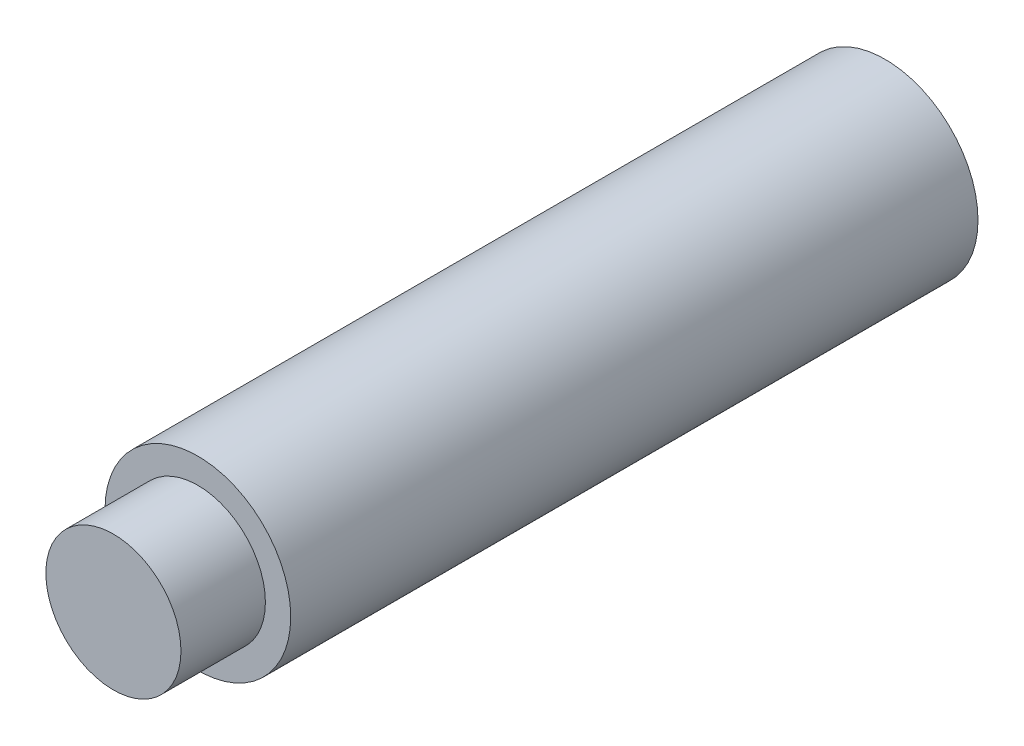
from build123d import *

# Parameters (mm, degrees)
TAP_DRILL_FOR_M6X1_0_TAP1_D     = 5
TAP_DRILL_FOR_M6X1_0_TAP1_DEPTH = 7
TAP_DRILL_FOR_M6X1_0_TAP1_TIP   = 1.502151548


with BuildPart() as part:
    # Sketch2 → Revolve1 (revolve)
    with BuildSketch(Plane(origin=(0, 0, 0), x_dir=(0, 0, -1), z_dir=(1, 0, 0))):
        Polygon((0, 0), (45.7, 0), (45.7, 5.5), (5, 5.5), (5, 4), (0, 4), align=None)
    revolve(axis=Axis((0, 0, 0), (0, 0, -1)))

    # Tap Drill for M6x1.0 Tap1
    with Locations(Plane(origin=(0, 0, -45.7), x_dir=(-1, 0, 0), z_dir=(0, 0, -1))):
        with Locations((0, 0)):
            Hole(TAP_DRILL_FOR_M6X1_0_TAP1_D / 2, depth=TAP_DRILL_FOR_M6X1_0_TAP1_DEPTH)
            with Locations((0, 0, -(TAP_DRILL_FOR_M6X1_0_TAP1_DEPTH + TAP_DRILL_FOR_M6X1_0_TAP1_TIP / 2))):  # 118° drill point
                Cone(0, TAP_DRILL_FOR_M6X1_0_TAP1_D / 2, TAP_DRILL_FOR_M6X1_0_TAP1_TIP, mode=Mode.SUBTRACT)


solid = part.part
